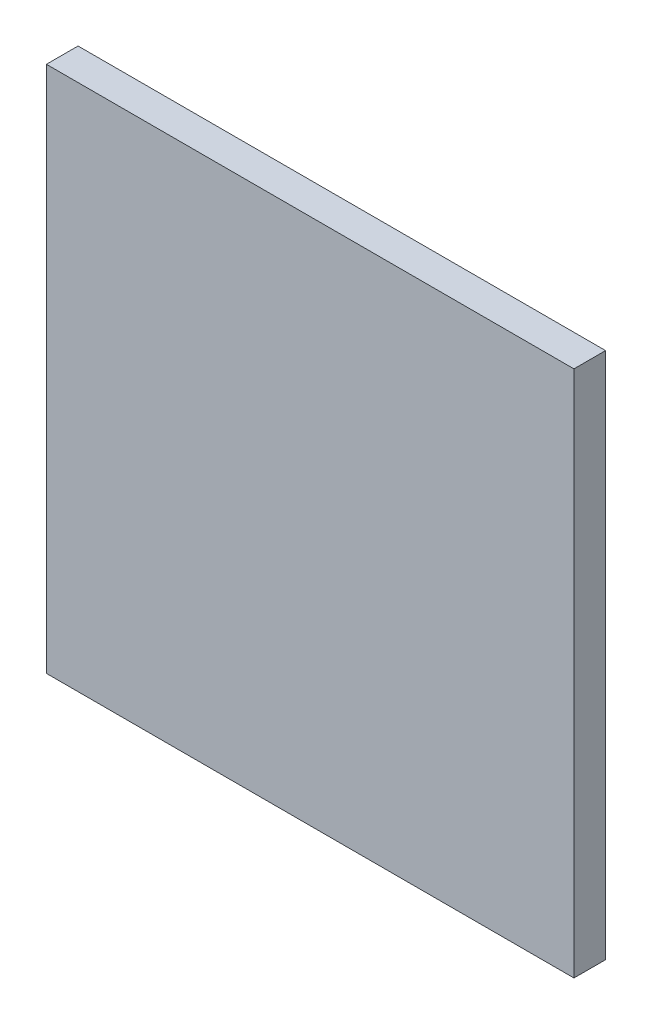
from build123d import *

# Parameters (mm, degrees)
SKETCH1_W           = 50
SKETCH1_H           = 50
BOSS_EXTRUDE1_DEPTH = 3


with BuildPart() as part:
    # Sketch1 → Boss-Extrude1 (new body)
    with BuildSketch(Plane.XY):
        Rectangle(SKETCH1_W, SKETCH1_H)
    extrude(amount=BOSS_EXTRUDE1_DEPTH)


solid = part.part
